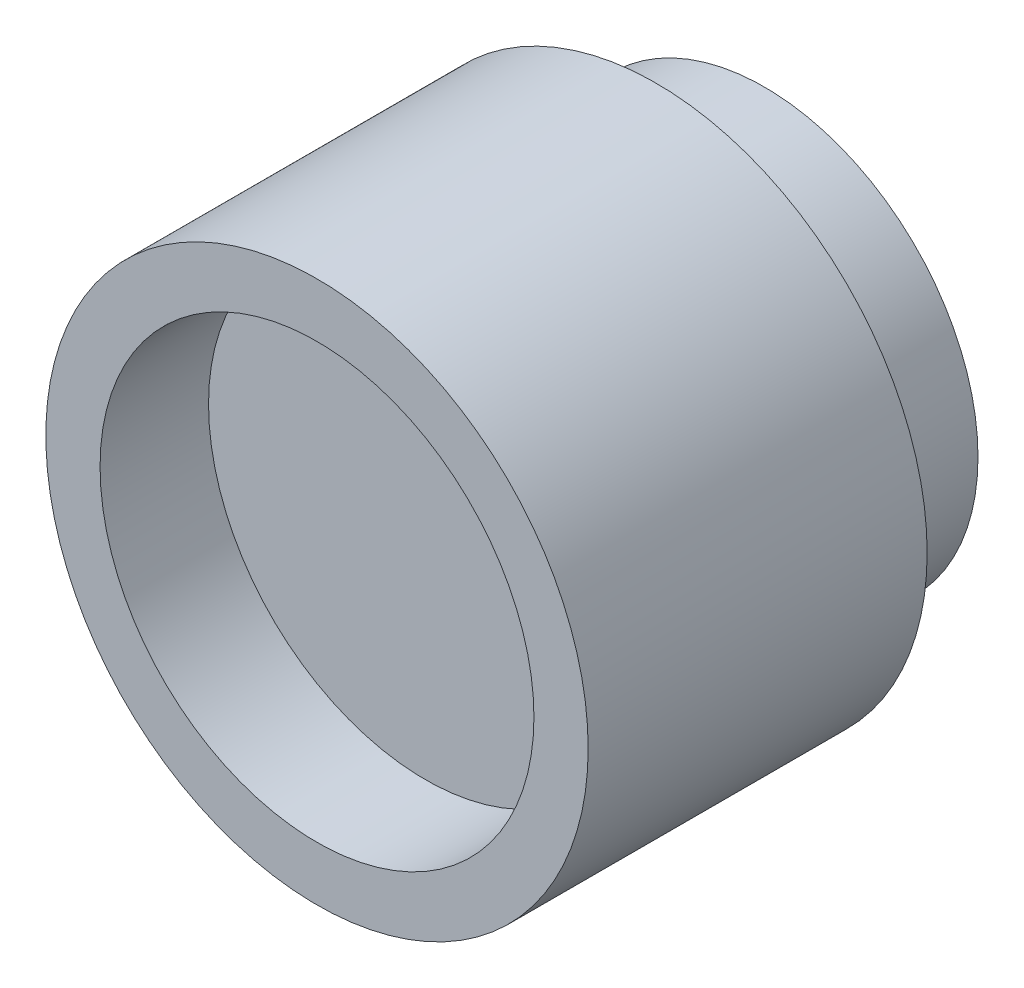
from build123d import *

# Parameters (mm, degrees)
SKETCH1_R           = 15.75
BOSS_EXTRUDE1_DEPTH = 33
SKETCH2_R           = 20
BOSS_EXTRUDE2_DEPTH = 25
SKETCH3_R           = 16
CUT_EXTRUDE1_DEPTH  = 8


with BuildPart() as part:
    # Sketch1 → Boss-Extrude1 (new body)
    with BuildSketch(Plane.XY):
        Circle(SKETCH1_R)
    extrude(amount=BOSS_EXTRUDE1_DEPTH)

    # Sketch2 → Boss-Extrude2 (add)
    with BuildSketch(Plane.XY.offset(33)):
        Circle(SKETCH2_R)
    extrude(amount=-BOSS_EXTRUDE2_DEPTH)

    # Sketch3 → Cut-Extrude1 (cut)
    with BuildSketch(Plane.XY.offset(33)):
        Circle(SKETCH3_R)
    extrude(amount=-CUT_EXTRUDE1_DEPTH, mode=Mode.SUBTRACT)


solid = part.part
